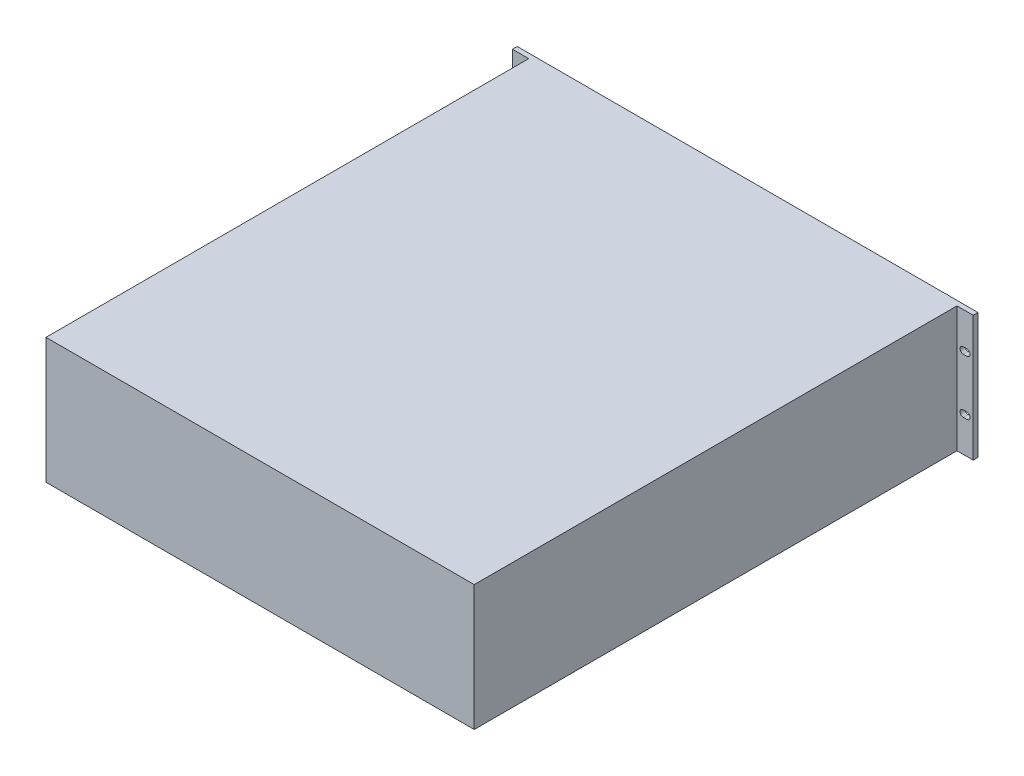
from build123d import *

# Parameters (mm, degrees)
SKETCH1_W           = 448
SKETCH1_H           = 131.3
BOSS_EXTRUDE1_DEPTH = 510
SKETCH2_W           = 482
SKETCH2_H           = 131.3
BOSS_EXTRUDE2_DEPTH = 5
CUT_EXTRUDE1_DEPTH  = 511


with BuildPart() as part:
    # Sketch1 → Boss-Extrude1 (new body)
    with BuildSketch(Plane.XY):
        Rectangle(SKETCH1_W, SKETCH1_H)
    extrude(amount=BOSS_EXTRUDE1_DEPTH)

    # Sketch2 → Boss-Extrude2 (add)
    with BuildSketch(Plane(origin=(0, 0, 0), x_dir=(-1, 0, 0), z_dir=(0, 0, -1))):
        Rectangle(SKETCH2_W, SKETCH2_H)
    extrude(amount=-BOSS_EXTRUDE2_DEPTH)

    # Sketch3 → Cut-Extrude1 (cut, through all)
    with BuildSketch(Plane(origin=(0, 0, 0), x_dir=(-1, 0, 0), z_dir=(0, 0, -1))):
        with BuildLine():
            Line((-234.4, 31.975), (-230.6, 31.975))
            ThreePointArc((-230.6, 31.975), (-227.2, 28.575), (-230.6, 25.175))
            Line((-230.6, 25.175), (-234.4, 25.175))
            ThreePointArc((-234.4, 25.175), (-237.8, 28.575), (-234.4, 31.975))
        make_face()
        with BuildLine():
            Line((234.4, 25.175), (230.6, 25.175))
            ThreePointArc((230.6, 25.175), (227.2, 28.575), (230.6, 31.975))
            Line((230.6, 31.975), (234.4, 31.975))
            ThreePointArc((234.4, 31.975), (237.8, 28.575), (234.4, 25.175))
        make_face()
    cut_extrude1 = extrude(amount=-CUT_EXTRUDE1_DEPTH, mode=Mode.SUBTRACT)

    # Mirror1: Cut-Extrude1 across plane
    add(cut_extrude1.mirror(Plane.ZX), mode=Mode.SUBTRACT)


solid = part.part
